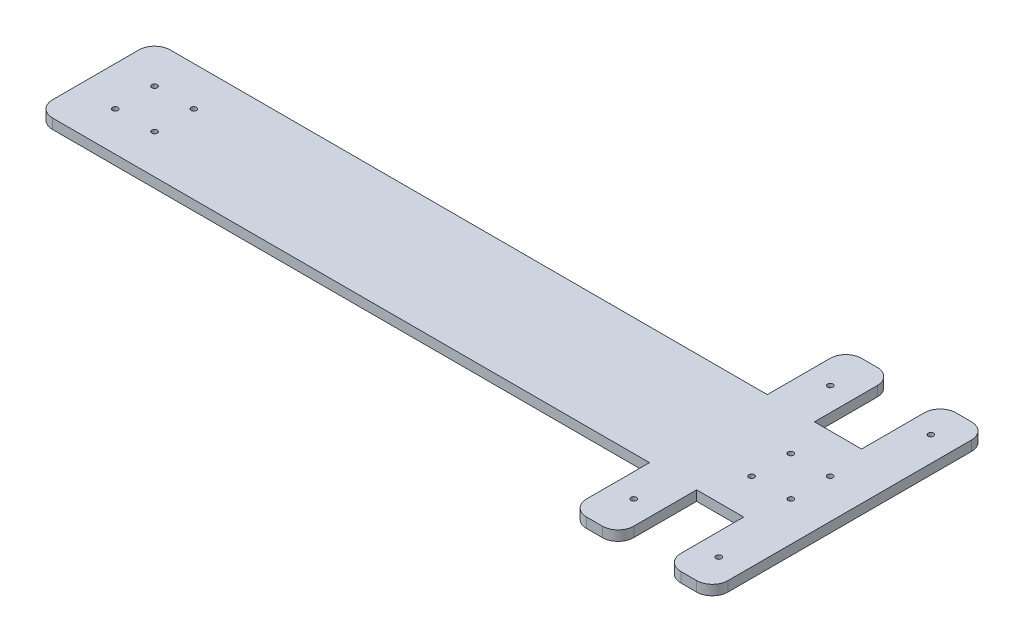
from build123d import *

# Parameters (mm, degrees)
BOSS_EXTRUDE2_DEPTH       = 6.35
SKETCH2_R                 = 1.75
CUT_EXTRUDE1_DEPTH        = 6.35
LPATTERN1_COUNT           = 2
LPATTERN1_PITCH           = 25
LPATTERN2_COUNT           = 2
LPATTERN2_PITCH           = 25
LPATTERN2_COPY_1_SKETCH_R = 1.75
LPATTERN2_COPY_1_DEPTH    = 6.35
FILLET1_R                 = 10
SKETCH3_R                 = 1.75
CUT_EXTRUDE2_DEPTH        = 7.35
SKETCH5_R                 = 1.75
CUT_EXTRUDE3_DEPTH        = 7.35
LPATTERN3_COUNT           = 2
LPATTERN3_PITCH           = 405
LPATTERN3_COPY_1_SKETCH_R = 1.75
LPATTERN3_COPY_1_DEPTH    = 6.35
LPATTERN3_COPY_2_SKETCH_R = 1.75
LPATTERN3_COPY_2_DEPTH    = 6.35
LPATTERN3_COPY_3_SKETCH_R = 1.75
LPATTERN3_COPY_3_DEPTH    = 6.35


with BuildPart() as part:
    # Sketch1 → Boss-Extrude2 (new body)
    with BuildSketch(Plane(origin=(0, 0, 0), x_dir=(1, 0, 0), z_dir=(0, 1, 0))):
        Polygon((-240, 37.5), (150, 37.5), (150, 87.5), (180, 87.5), (180, 37.5), (210, 37.5), (210, 87.5), (240, 87.5), (240, -87.5), (210, -87.5), (210, -37.5), (180, -37.5), (180, -87.5), (150, -87.5), (150, -37.5), (-240, -37.5), align=None)
    extrude(amount=BOSS_EXTRUDE2_DEPTH)

    # Sketch2 → Cut-Extrude1 (cut)
    with BuildSketch(Plane(origin=(0, 6.35, 0), x_dir=(1, 0, 0), z_dir=(0, 1, 0))):
        with Locations((190, 12.5)):
            Circle(SKETCH2_R)
    cut_extrude1 = extrude(amount=-CUT_EXTRUDE1_DEPTH, mode=Mode.SUBTRACT)

    # LPattern1: Cut-Extrude1 ×2
    with Locations(*[(i * LPATTERN1_PITCH, 0, 0) for i in range(1, LPATTERN1_COUNT)]):
        add(cut_extrude1, mode=Mode.SUBTRACT)

    # LPattern2: Cut-Extrude1 ×2
    with Locations(*[(0, 0, i * LPATTERN2_PITCH) for i in range(1, LPATTERN2_COUNT)]):
        add(cut_extrude1, mode=Mode.SUBTRACT)

    # LPattern2 copy 1 sketch → LPattern2 copy 1 (cut)
    with BuildSketch(Plane(origin=(25, 6.35, 25), x_dir=(1, 0, 0), z_dir=(0, 1, 0))):
        with Locations((190, 12.5)):
            Circle(LPATTERN2_COPY_1_SKETCH_R)
    extrude(amount=-LPATTERN2_COPY_1_DEPTH, mode=Mode.SUBTRACT)

    # Fillet1
    fillet1_edges = [part.edges().sort_by_distance(p)[0] for p in [
        (-240, 3.175, -37.5),
        (150, 3.175, -87.5),
        (180, 3.175, -87.5),
        (210, 3.175, -87.5),
        (240, 3.175, -87.5),
        (240, 3.175, 87.5),
        (210, 3.175, 87.5),
        (180, 3.175, 87.5),
        (150, 3.175, 87.5),
        (-240, 3.175, 37.5),
    ]]
    fillet(fillet1_edges, radius=FILLET1_R)

    # Sketch3 → Cut-Extrude2 (cut, through all)
    with BuildSketch(Plane(origin=(0, 6.35, 0), x_dir=(1, 0, 0), z_dir=(0, 1, 0))):
        with Locations((224.12, 67.5)):
            Circle(SKETCH3_R)
        with Locations((224.12, -67.5)):
            Circle(SKETCH3_R)
    extrude(amount=-CUT_EXTRUDE2_DEPTH, mode=Mode.SUBTRACT)

    # Sketch5 → Cut-Extrude3 (cut, through all)
    with BuildSketch(Plane(origin=(0, 6.35, 0), x_dir=(1, 0, 0), z_dir=(0, 1, 0))):
        with Locations((165, 62.5)):
            Circle(SKETCH5_R)
        with Locations((165, -62.5)):
            Circle(SKETCH5_R)
    extrude(amount=-CUT_EXTRUDE3_DEPTH, mode=Mode.SUBTRACT)

    # LPattern3: Cut-Extrude1 ×2
    with Locations(*[(-i * LPATTERN3_PITCH, 0, 0) for i in range(1, LPATTERN3_COUNT)]):
        add(cut_extrude1, mode=Mode.SUBTRACT)

    # LPattern3 copy 1 sketch → LPattern3 copy 1 (cut)
    with BuildSketch(Plane(origin=(-405, 6.35, 25), x_dir=(1, 0, 0), z_dir=(0, 1, 0))):
        with Locations((190, 12.5)):
            Circle(LPATTERN3_COPY_1_SKETCH_R)
    extrude(amount=-LPATTERN3_COPY_1_DEPTH, mode=Mode.SUBTRACT)

    # LPattern3 copy 2 sketch → LPattern3 copy 2 (cut)
    with BuildSketch(Plane(origin=(-380, 6.35, 25), x_dir=(1, 0, 0), z_dir=(0, 1, 0))):
        with Locations((190, 12.5)):
            Circle(LPATTERN3_COPY_2_SKETCH_R)
    extrude(amount=-LPATTERN3_COPY_2_DEPTH, mode=Mode.SUBTRACT)

    # LPattern3 copy 3 sketch → LPattern3 copy 3 (cut)
    with BuildSketch(Plane(origin=(-380, 6.35, 0), x_dir=(1, 0, 0), z_dir=(0, 1, 0))):
        with Locations((190, 12.5)):
            Circle(LPATTERN3_COPY_3_SKETCH_R)
    extrude(amount=-LPATTERN3_COPY_3_DEPTH, mode=Mode.SUBTRACT)


solid = part.part
